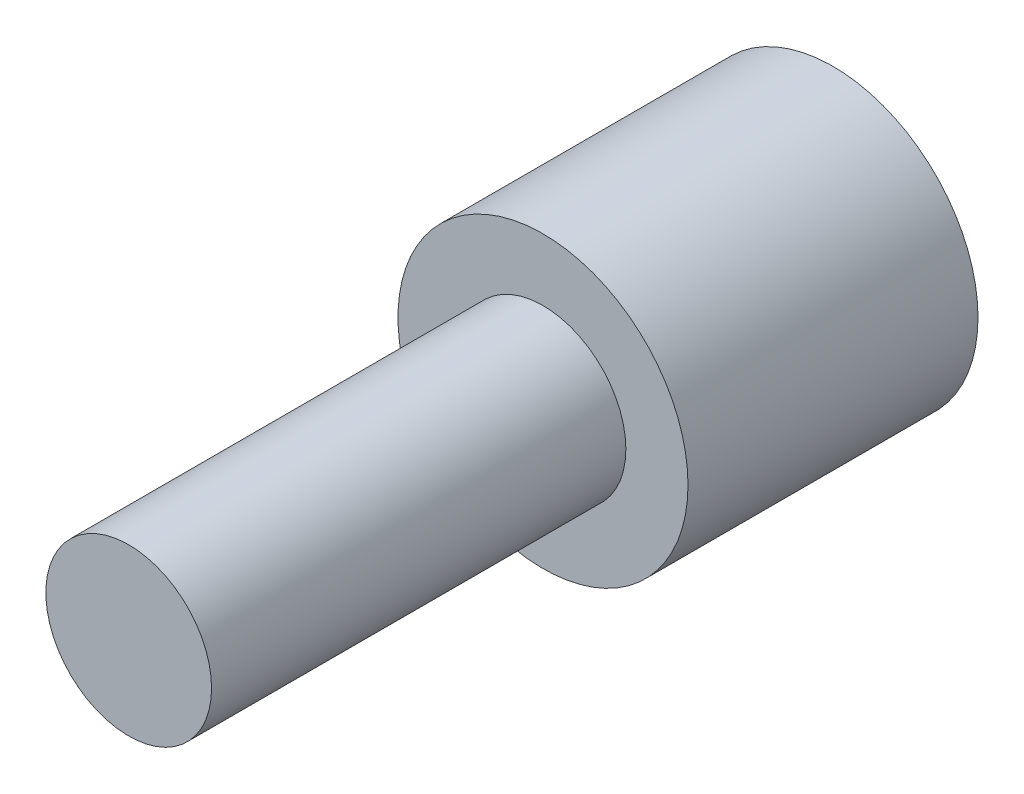
from build123d import *

# Parameters (mm, degrees)
ESQUISSE1_R             = 3.5
BOSS_EXTRU_1_DEPTH      = 7
ESQUISSE2_R             = 2.9
ENL_V_MAT_EXTRU_1_DEPTH = 2.5
ESQUISSE3_R             = 2
BOSS_EXTRU_2_DEPTH      = 10


with BuildPart() as part:
    # Esquisse1 → Boss.-Extru.1 (new body)
    with BuildSketch(Plane.XY):
        Circle(ESQUISSE1_R)
    extrude(amount=BOSS_EXTRU_1_DEPTH)

    # Esquisse2 → Enlèv. mat.-Extru.1 (cut)
    with BuildSketch(Plane(origin=(0, 0, 0), x_dir=(-1, 0, 0), z_dir=(0, 0, -1))):
        Circle(ESQUISSE2_R)
    extrude(amount=-ENL_V_MAT_EXTRU_1_DEPTH, mode=Mode.SUBTRACT)

    # Esquisse3 → Boss.-Extru.2 (add)
    with BuildSketch(Plane.XY.offset(7)):
        Circle(ESQUISSE3_R)
    extrude(amount=BOSS_EXTRU_2_DEPTH)


solid = part.part
